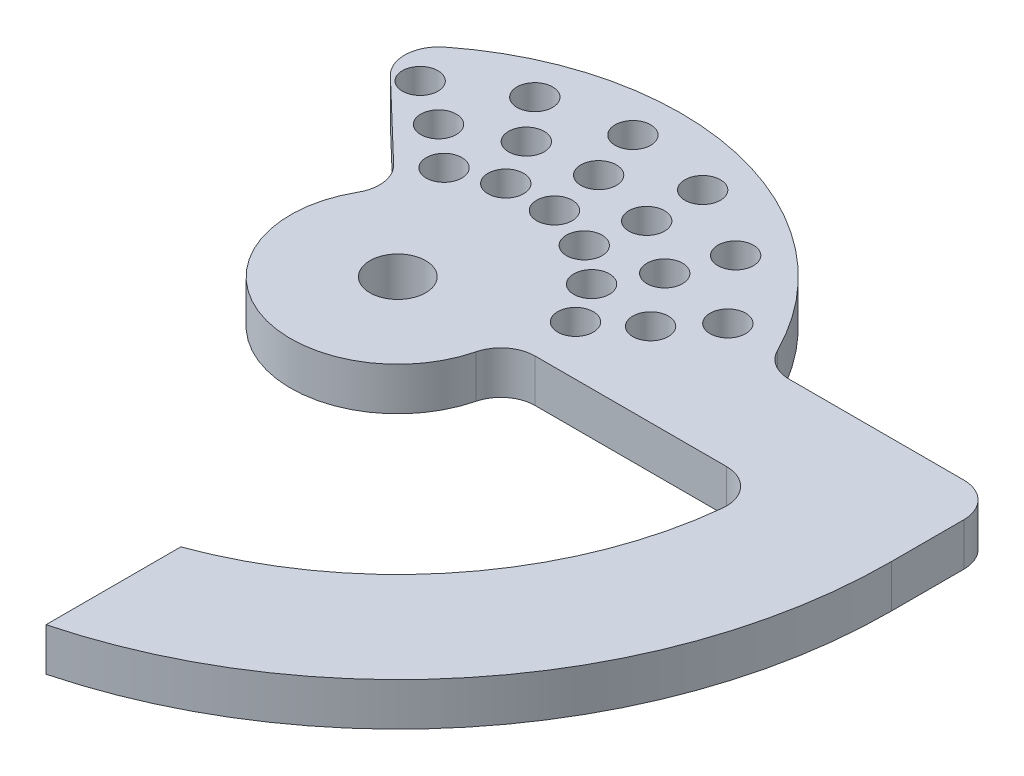
from build123d import *

# Parameters (mm, degrees)
SKETCH1_R               = 12.5
BOSS_EXTRUDE1_DEPTH     = 5
EXTRUDE_THIN1_DEPTH     = 5
SKETCH6_W               = 56.5
SKETCH6_H               = 12.459935794
BOSS_EXTRUDE3_DEPTH     = 5
SKETCH7_R               = 3.25
CUT_EXTRUDE3_DEPTH      = 1
CUT_EXTRUDE3_DEPTH_BACK = 6
BOSS_EXTRUDE4_DEPTH     = 5
SKETCH9_4_W             = 9.626496109
SKETCH9_4_H             = 23.122525611
CUT_EXTRUDE5_DEPTH      = 6
BOSS_EXTRUDE5_DEPTH     = 5
SKETCH11_R              = 2.075
CUT_EXTRUDE6_DEPTH      = 6
SKETCH12_R              = 2.075
CUT_EXTRUDE7_DEPTH      = 6
SKETCH13_R              = 2.075
CUT_EXTRUDE8_DEPTH      = 6
CIRPATTERN1_COUNT       = 6
CIRPATTERN1_ANGLE       = 100
CIRPATTERN2_COUNT       = 6
CIRPATTERN2_ANGLE       = 100
CIRPATTERN3_COUNT       = 6
CIRPATTERN3_ANGLE       = 100
FILLET2_R               = 4


with BuildPart() as part:
    # Sketch1 → Boss-Extrude1 (new body)
    with BuildSketch(Plane(origin=(0, 0, 0), x_dir=(1, 0, 0), z_dir=(0, 1, 0))):
        Circle(SKETCH1_R)
    extrude(amount=BOSS_EXTRUDE1_DEPTH)



with BuildPart() as body_2:
    # Sketch4 → Extrude-Thin1 (new body)
    with BuildSketch(Plane(origin=(0, 0, 0), x_dir=(1, 0, 0), z_dir=(0, 1, 0))):
        with BuildLine():
            ThreePointArc((16.811373022, -54.987523468), (46.221769485, -34.202310238), (57.5, 0))
            Line((57.5, 0), (42.5, 0))
            ThreePointArc((42.5, 0), (34.163916576, -25.279968437), (12.425797451, -40.642952128))
            Line((12.425797451, -40.642952128), (16.811373022, -54.987523468))
        make_face()
    extrude(amount=EXTRUDE_THIN1_DEPTH)


with BuildPart() as part_1:
    add(part.part)

    add(body_2.part)  # Boss-Extrude3 merges body 2
    # Sketch6 → Boss-Extrude3 (add)
    with BuildSketch(Plane(origin=(0, 0, 0), x_dir=(1, 0, 0), z_dir=(0, 1, 0))):
        with Locations((29.25, 6.229967897)):
            Rectangle(SKETCH6_W, SKETCH6_H)
    extrude(amount=BOSS_EXTRUDE3_DEPTH)

    # Sketch7 → Cut-Extrude3 (cut, two sides)
    with BuildSketch(Plane(origin=(0, 5, 0), x_dir=(1, 0, 0), z_dir=(0, 1, 0))) as cut_extrude3_sk:
        Circle(SKETCH7_R)
    extrude(amount=CUT_EXTRUDE3_DEPTH, mode=Mode.SUBTRACT)
    extrude(cut_extrude3_sk.sketch, amount=-CUT_EXTRUDE3_DEPTH_BACK, mode=Mode.SUBTRACT)

    # Sketch9 → Boss-Extrude4 (add)
    with BuildSketch(Plane(origin=(0, 0, 0), x_dir=(1, 0, 0), z_dir=(0, 1, 0))):
        with BuildLine():
            Line((16.811373022, -54.987523468), (14.618585236, -47.815237798))
            Line((14.618585236, -47.815237798), (14.618585236, -55.610673128))
            ThreePointArc((14.618585236, -55.610673128), (15.718067562, -55.309966119), (16.811373022, -54.987523468))
        make_face()
        with BuildLine():
            Line((14.618585236, -47.815237798), (12.425797451, -40.642952128))
            Line((12.425797451, -40.642952128), (11.862973877, -56.262952738))
            ThreePointArc((11.862973877, -56.262952738), (13.244795598, -55.953779046), (14.618585236, -55.610673128))
            Line((14.618585236, -55.610673128), (14.618585236, -47.815237798))
        make_face()
    extrude(amount=BOSS_EXTRUDE4_DEPTH)

    # Sketch9_4 → Cut-Extrude5 (cut, through all)
    with BuildSketch(Plane(origin=(0, 0, 0), x_dir=(1, 0, 0), z_dir=(0, 1, 0))):
        with Locations((9.805337182, -49.150976699)):
            Rectangle(SKETCH9_4_W, SKETCH9_4_H)
    extrude(amount=CUT_EXTRUDE5_DEPTH, mode=Mode.SUBTRACT)

    # Sketch10 → Boss-Extrude5 (add)
    with BuildSketch(Plane(origin=(0, 0, 0), x_dir=(1, 0, 0), z_dir=(0, 1, 0))):
        with BuildLine():
            Line((-23.827361095, 22.831050419), (-5.931209267, 5.683203326))
            Line((-5.931209267, 5.683203326), (19.532104398, 5.683203326))
            Line((19.532104398, 5.683203326), (31.685950206, 9.219574804))
            ThreePointArc((31.685950206, 9.219574804), (7.85858911, 32.050625223), (-23.827361095, 22.831050419))
        make_face()
    extrude(amount=BOSS_EXTRUDE5_DEPTH)

    # Sketch11 → Cut-Extrude6 (cut, through all)
    with BuildSketch(Plane(origin=(0, 5, 0), x_dir=(1, 0, 0), z_dir=(0, 1, 0))):
        with Locations((-8.29398923, 13.682461133)):
            Circle(SKETCH11_R)
    cut_extrude6 = extrude(amount=-CUT_EXTRUDE6_DEPTH, mode=Mode.SUBTRACT)

    # Sketch12 → Cut-Extrude7 (cut, through all)
    with BuildSketch(Plane(origin=(0, 5, 0), x_dir=(1, 0, 0), z_dir=(0, 1, 0))):
        with Locations((-13.000533094, 17.747848863)):
            Circle(SKETCH12_R)
    cut_extrude7 = extrude(amount=-CUT_EXTRUDE7_DEPTH, mode=Mode.SUBTRACT)

    # Sketch13 → Cut-Extrude8 (cut, through all)
    with BuildSketch(Plane(origin=(0, 5, 0), x_dir=(1, 0, 0), z_dir=(0, 1, 0))):
        with Locations((-18.451858843, 21.060125955)):
            Circle(SKETCH13_R)
    cut_extrude8 = extrude(amount=-CUT_EXTRUDE8_DEPTH, mode=Mode.SUBTRACT)

    # CirPattern1: Cut-Extrude6 ×6 about axis
    cirpattern1_axis = Axis((0, 0, 0), (0, -1, 0))
    for i in range(1, CIRPATTERN1_COUNT):
        add(cut_extrude6.rotate(cirpattern1_axis, i * CIRPATTERN1_ANGLE / (CIRPATTERN1_COUNT - 1)), mode=Mode.SUBTRACT)

    # CirPattern2: Cut-Extrude7 ×6 about axis
    cirpattern2_axis = Axis((0, 0, 0), (0, -1, 0))
    for i in range(1, CIRPATTERN2_COUNT):
        add(cut_extrude7.rotate(cirpattern2_axis, i * CIRPATTERN2_ANGLE / (CIRPATTERN2_COUNT - 1)), mode=Mode.SUBTRACT)

    # CirPattern3: Cut-Extrude8 ×6 about axis
    cirpattern3_axis = Axis((0, 0, 0), (0, -1, 0))
    for i in range(1, CIRPATTERN3_COUNT):
        add(cut_extrude8.rotate(cirpattern3_axis, i * CIRPATTERN3_ANGLE / (CIRPATTERN3_COUNT - 1)), mode=Mode.SUBTRACT)

    # Fillet2
    fillet2_edges = [part_1.edges().sort_by_distance(p)[0] for p in [
        (42.5, 2.5, 0),
        (30.557323181, 2.5, -12.459935794),
        (-9.025515566, 2.5, -8.648125159),
        (-23.827361095, 2.5, -22.831050419),
        (12.5, 2.5, 0),
        (57.5, 2.5, -12.459935794),
    ]]
    fillet(fillet2_edges, radius=FILLET2_R)


solid = part_1.part
